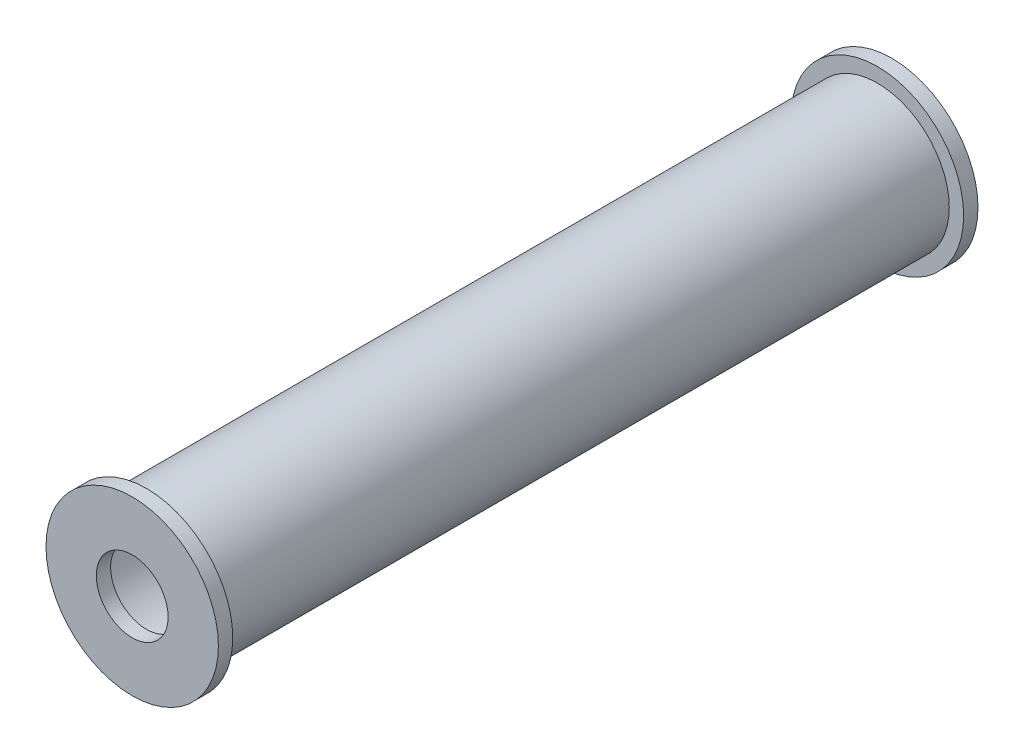
from build123d import *

# Parameters (mm, degrees)
SKETCH1_R           = 5
SKETCH1_R_2         = 4.5
BOSS_EXTRUDE1_DEPTH = 50.87650029
SKETCH2_R           = 6
SKETCH2_R_2         = 2.5
BOSS_EXTRUDE2_DEPTH = 1
SKETCH3_R           = 6
SKETCH3_R_2         = 2.5
BOSS_EXTRUDE3_DEPTH = 1


with BuildPart() as part:
    # Sketch1 → Boss-Extrude1 (new body)
    with BuildSketch(Plane.XY):
        Circle(SKETCH1_R)
        Circle(SKETCH1_R_2, mode=Mode.SUBTRACT)
    extrude(amount=BOSS_EXTRUDE1_DEPTH)

    # Sketch2 → Boss-Extrude2 (add)
    with BuildSketch(Plane(origin=(0, 0, 0), x_dir=(-1, 0, 0), z_dir=(0, 0, -1))):
        Circle(SKETCH2_R)
        Circle(SKETCH2_R_2, mode=Mode.SUBTRACT)
    extrude(amount=BOSS_EXTRUDE2_DEPTH)

    # Sketch3 → Boss-Extrude3 (add)
    with BuildSketch(Plane.XY.offset(50.87650029)):
        Circle(SKETCH3_R)
        Circle(SKETCH3_R_2, mode=Mode.SUBTRACT)
    extrude(amount=BOSS_EXTRUDE3_DEPTH)


solid = part.part
